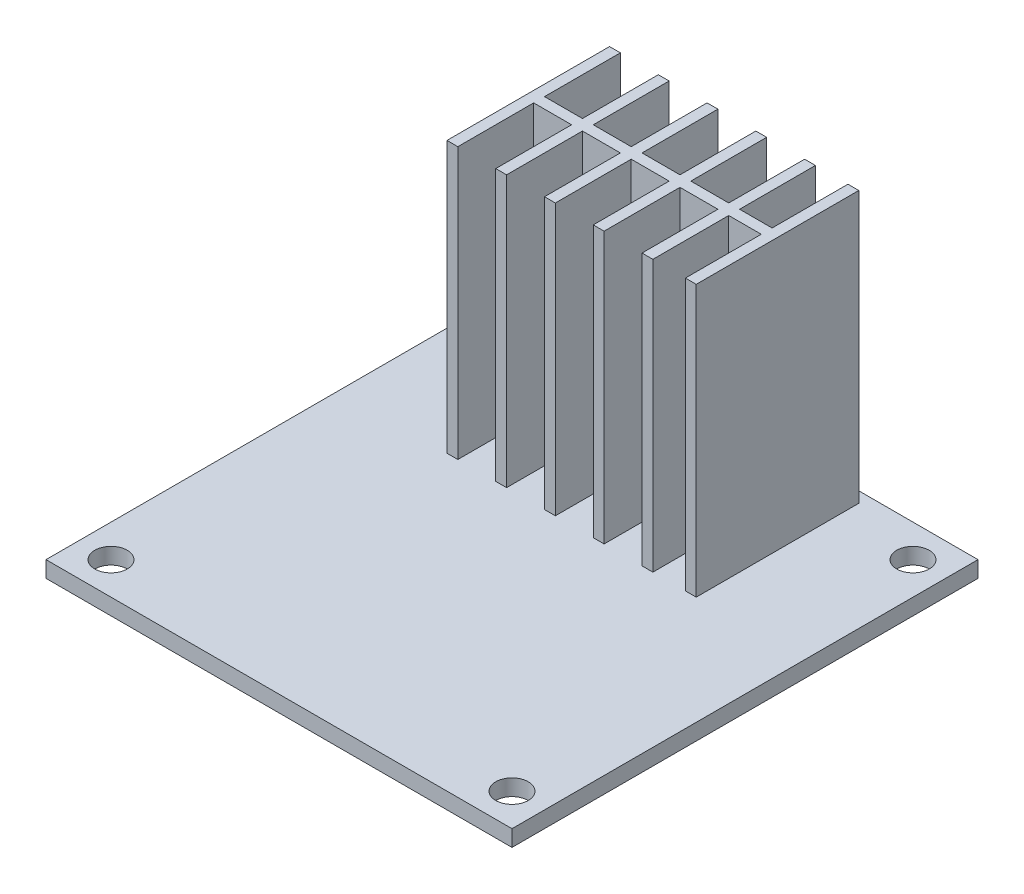
from build123d import *

# Parameters (mm, degrees)
SKETCH1_W           = 43
SKETCH1_H           = 43
BOSS_EXTRUDE1_DEPTH = 1.5
SKETCH2_R           = 1.5
CUT_EXTRUDE1_DEPTH  = 2.5
BOSS_EXTRUDE2_DEPTH = 25


with BuildPart() as part:
    # Sketch1 → Boss-Extrude1 (new body)
    with BuildSketch(Plane(origin=(0, 0, 0), x_dir=(1, 0, 0), z_dir=(0, 1, 0))):
        Rectangle(SKETCH1_W, SKETCH1_H)
    extrude(amount=BOSS_EXTRUDE1_DEPTH)

    # Sketch2 → Cut-Extrude1 (cut, through all)
    with BuildSketch(Plane(origin=(0, 1.5, 0), x_dir=(1, 0, 0), z_dir=(0, 1, 0))):
        with Locations((-18.5, 18.5)):
            Circle(SKETCH2_R)
        with Locations((18.5, 18.5)):
            Circle(SKETCH2_R)
        with Locations((18.5, -18.5)):
            Circle(SKETCH2_R)
        with Locations((-18.5, -18.5)):
            Circle(SKETCH2_R)
    extrude(amount=-CUT_EXTRUDE1_DEPTH, mode=Mode.SUBTRACT)

    # Sketch3 → Boss-Extrude2 (add)
    with BuildSketch(Plane(origin=(0, 1.5, 0), x_dir=(1, 0, 0), z_dir=(0, 1, 0))):
        Polygon((-7, 5.5), (-7, 12.5), (-10.5, 12.5), (-10.5, 5.5), (-11.5, 5.5), (-11.5, 20.5), (-10.5, 20.5), (-10.5, 13.5), (-7, 13.5), (-7, 20.5), (-6, 20.5), (-6, 13.5), (-2.5, 13.5), (-2.5, 20.5), (-1.5, 20.5), (-1.5, 13.5), (2, 13.5), (2, 20.5), (3, 20.5), (3, 13.5), (6.5, 13.5), (6.5, 20.5), (7.5, 20.5), (7.5, 13.5), (10.5, 13.5), (10.5, 20.5), (11.5, 20.5), (11.5, 5.5), (10.5, 5.5), (10.5, 12.5), (7.5, 12.5), (7.5, 5.5), (6.5, 5.5), (6.5, 12.5), (3, 12.5), (3, 5.5), (2, 5.5), (2, 12.5), (-1.5, 12.5), (-1.5, 5.5), (-2.5, 5.5), (-2.5, 12.5), (-6, 12.5), (-6, 5.5), align=None)
    extrude(amount=BOSS_EXTRUDE2_DEPTH)


solid = part.part
